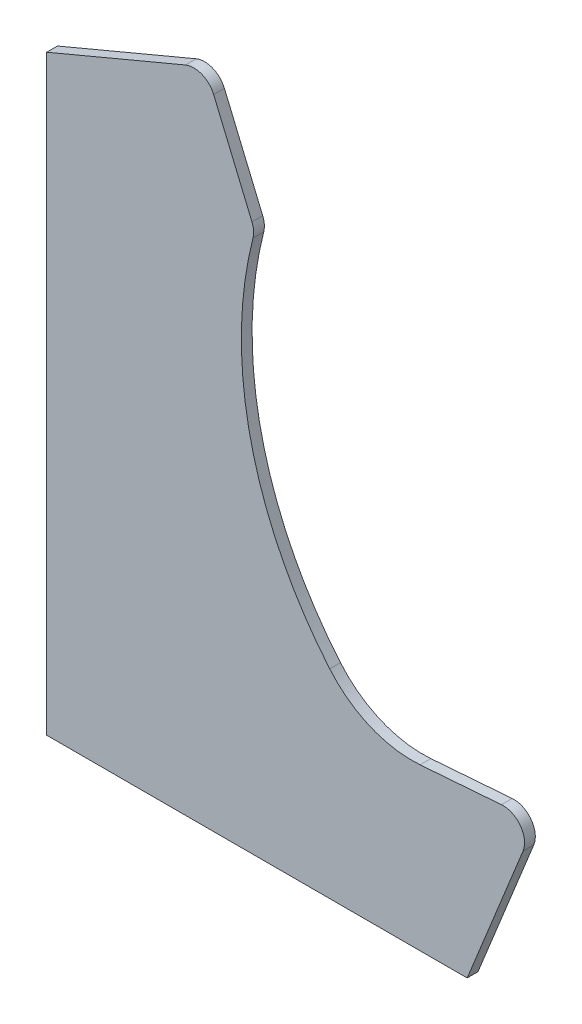
from build123d import *

# Parameters (mm, degrees)
BOSS_EXTRU_1_DEPTH = 10


with BuildPart() as part:
    # Esquisse1 → Boss.-Extru.1 (new body)
    with BuildSketch(Plane.XY):
        with BuildLine():
            Line((0, 0), (0, 550))
            Line((0, 550), (129.062590026, 604.250037842))
            ThreePointArc((129.062590026, 604.250037842), (144.369719008, 604.329896284), (155.249962158, 593.562590026))
            Line((155.249962158, 593.562590026), (190.859025666, 508.847479263))
            ThreePointArc((190.859025666, 508.847479263), (192.366539865, 502.580756708), (191.802553764, 496.159983364))
            ThreePointArc((191.802553764, 496.159983364), (189.838676364, 331.953031603), (263.189381841, 185.026336182))
            ThreePointArc((263.189381841, 185.026336182), (300.928689878, 157.28521303), (347.160451012, 149.771921656))
            Line((347.160451012, 149.771921656), (422.849515254, 155.480705177))
            ThreePointArc((422.849515254, 155.480705177), (440.508345068, 147.328376864), (442.889156647, 128.024841862))
            Line((442.889156647, 128.024841862), (391, 0))
            Line((391, 0), (0, 0))
        make_face()
    extrude(amount=BOSS_EXTRU_1_DEPTH)


solid = part.part
